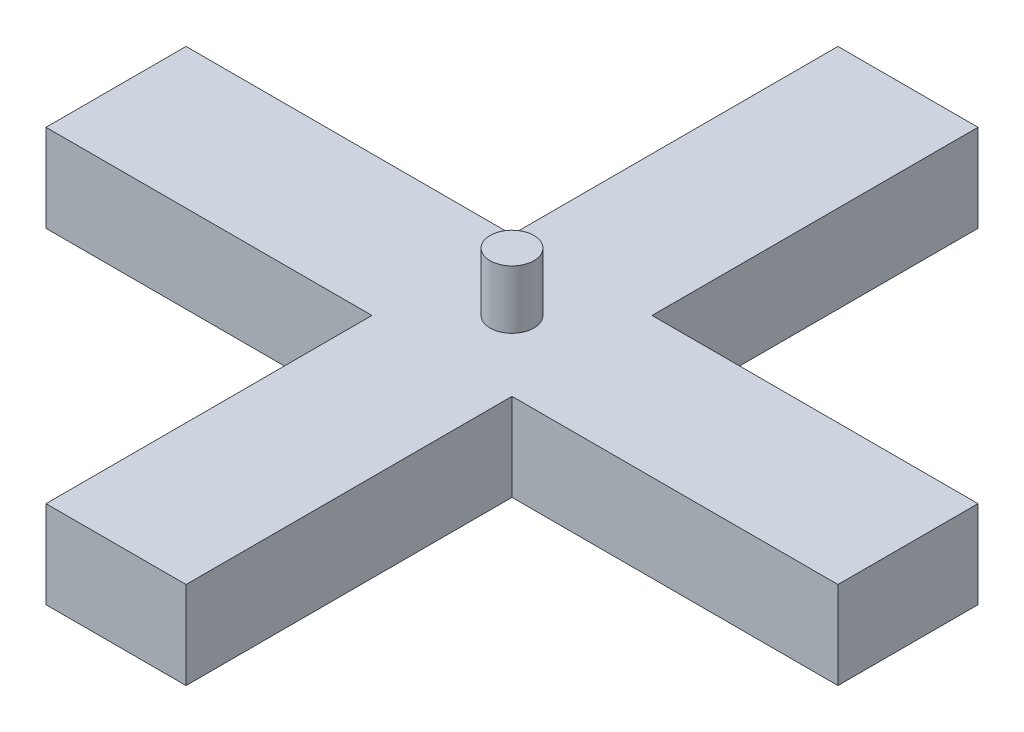
from build123d import *

# Parameters (mm, degrees)
SKETCH1_R           = 0.75
BOSS_EXTRUDE1_DEPTH = 5
SKETCH1_3_R         = 0.75
BOSS_EXTRUDE2_DEPTH = 3


with BuildPart() as part:
    # Sketch1 → Boss-Extrude1 (new body)
    with BuildSketch(Plane(origin=(0, 0, 0), x_dir=(1, 0, 0), z_dir=(0, 1, 0))):
        with Locations((-2.405620155, -5.519728682)):
            Circle(SKETCH1_R)
    extrude(amount=BOSS_EXTRUDE1_DEPTH)

    # Sketch1_3 → Boss-Extrude2 (add)
    with BuildSketch(Plane(origin=(0, 0, 0), x_dir=(1, 0, 0), z_dir=(0, 1, 0))):
        Polygon((-0.005620155, 8.050271318), (-4.805620155, 8.050271318), (-4.805620155, -3.119728682), (-15.975620155, -3.119728682), (-15.975620155, -7.919728682), (-4.805620155, -7.919728682), (-4.805620155, -19.089728682), (-0.005620155, -19.089728682), (-0.005620155, -7.919728682), (11.164379845, -7.919728682), (11.164379845, -3.119728682), (-0.005620155, -3.119728682), align=None)
        with Locations((-2.405620155, -5.519728682)):
            Circle(SKETCH1_3_R, mode=Mode.SUBTRACT)
    extrude(amount=BOSS_EXTRUDE2_DEPTH)


solid = part.part
